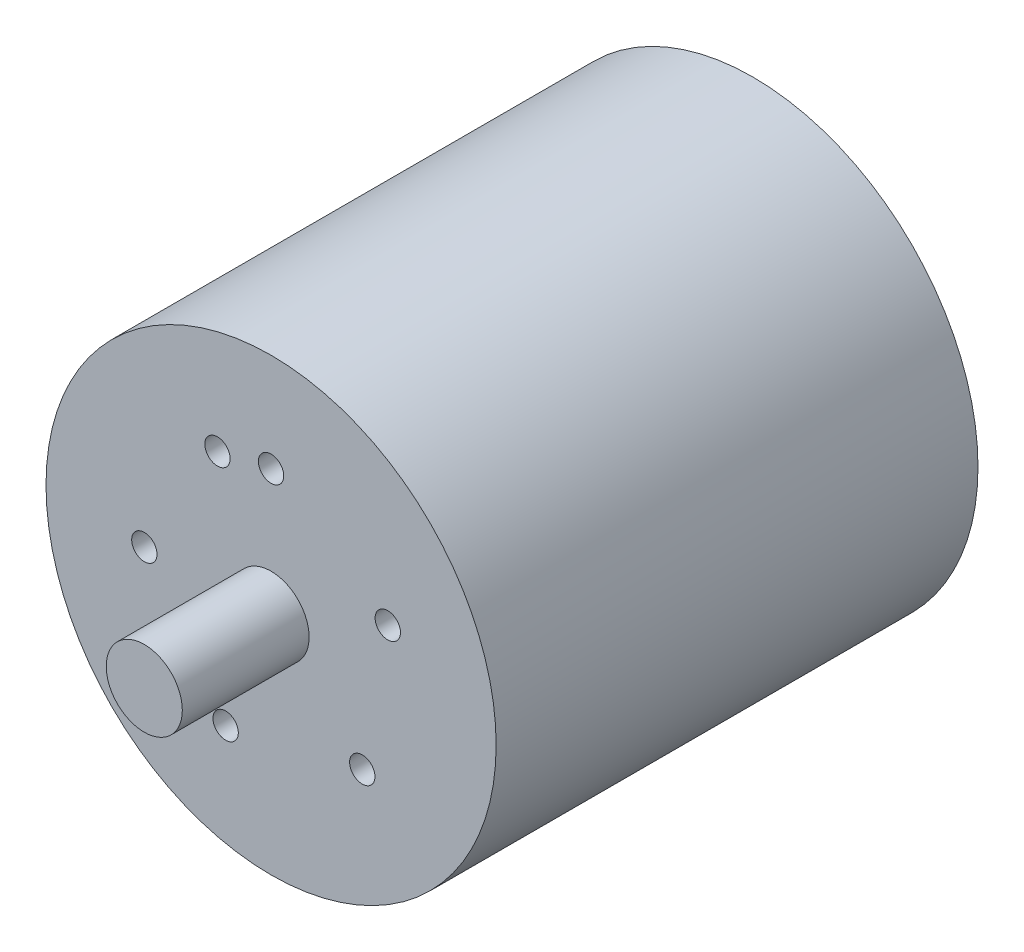
from build123d import *

# Parameters (mm, degrees)
SKETCH1_R           = 17.75
BOSS_EXTRUDE1_DEPTH = 19
SKETCH2_R           = 3
BOSS_EXTRUDE2_DEPTH = 10
SKETCH3_R           = 1
CUT_EXTRUDE1_DEPTH  = 2
CIRPATTERN1_COUNT   = 6
CIRPATTERN1_ANGLE   = 335


with BuildPart() as part:
    # Sketch1 → Boss-Extrude1 (new body, symmetric)
    with BuildSketch(Plane.XY):
        Circle(SKETCH1_R)
    extrude(amount=BOSS_EXTRUDE1_DEPTH, both=True)

    # Sketch2 → Boss-Extrude2 (add)
    with BuildSketch(Plane.XY.offset(19)):
        Circle(SKETCH2_R)
    extrude(amount=BOSS_EXTRUDE2_DEPTH)

    # Sketch3 → Cut-Extrude1 (cut)
    with BuildSketch(Plane.XY.offset(19)):
        with Locations((0, 10)):
            Circle(SKETCH3_R)
    cut_extrude1 = extrude(amount=-CUT_EXTRUDE1_DEPTH, mode=Mode.SUBTRACT)

    # CirPattern1: Cut-Extrude1 ×6 about axis
    cirpattern1_axis = Axis((0, 0, 0), (0, 0, -1))
    for i in range(1, CIRPATTERN1_COUNT):
        add(cut_extrude1.rotate(cirpattern1_axis, i * CIRPATTERN1_ANGLE / (CIRPATTERN1_COUNT - 1)), mode=Mode.SUBTRACT)


solid = part.part
